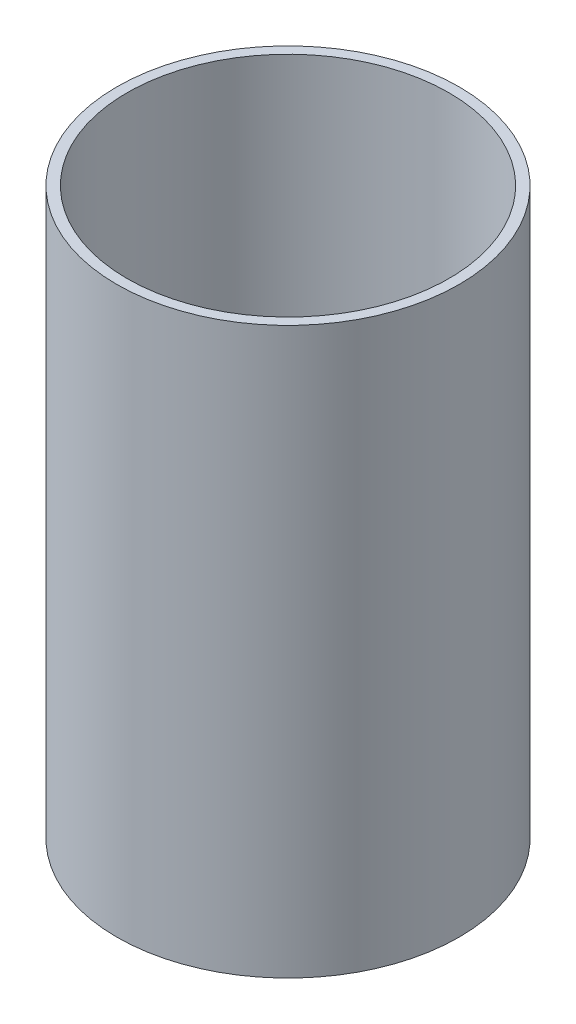
from build123d import *

# Parameters (mm, degrees)
SKETCH1_R           = 25.175
SKETCH1_R_2         = 23.675
BOSS_EXTRUDE1_DEPTH = 83.14


with BuildPart() as part:
    # Sketch1 → Boss-Extrude1 (new body)
    with BuildSketch(Plane(origin=(0, 0, 0), x_dir=(1, 0, 0), z_dir=(0, 1, 0))):
        Circle(SKETCH1_R)
        Circle(SKETCH1_R_2, mode=Mode.SUBTRACT)
    extrude(amount=BOSS_EXTRUDE1_DEPTH)


solid = part.part
